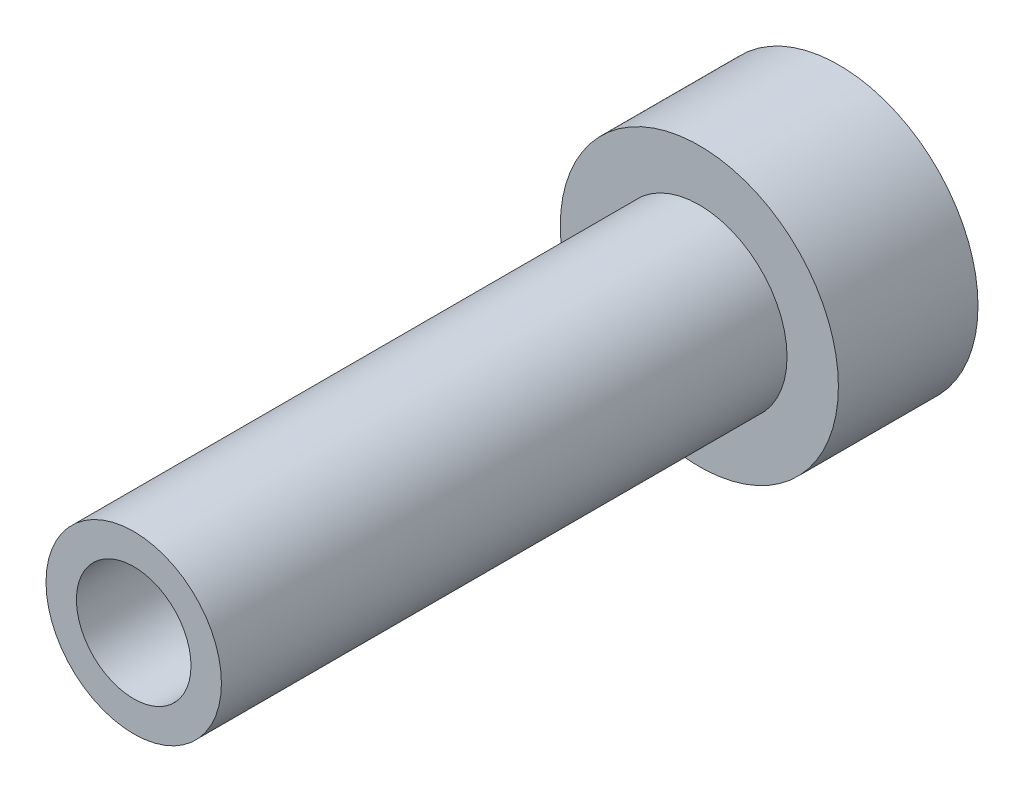
from build123d import *

# Parameters (mm, degrees)
BOSS_EXTRUDE1_START = 0.1
SKETCH1_R           = 3.884465816
BOSS_EXTRUDE1_DEPTH = 2.9
SKETCH2_R           = 3.884465816
SKETCH2_R_2         = 1.6
BOSS_EXTRUDE2_DEPTH = 1
SKETCH3_R           = 2.45
SKETCH3_R_2         = 1.6
BOSS_EXTRUDE3_DEPTH = 15.8


with BuildPart() as part:
    # Sketch1 → Boss-Extrude1 (new body)
    with BuildSketch(Plane.XY.offset(BOSS_EXTRUDE1_START)):
        with Locations((-0.001459351, 10.192904416)):
            Circle(SKETCH1_R)
        with BuildLine():
            Line((0.96845111, 13.081919272), (0.60411229, 12.721398629))
            ThreePointArc((0.60411229, 12.721398629), (0.587991908, 12.72520519), (0.571847603, 12.728908977))
            Line((0.571847603, 12.728908977), (0.404173908, 13.213267772))
            Line((0.404173908, 13.213267772), (0.114648145, 12.790310631))
            ThreePointArc((0.114648145, 12.790310631), (0.098098683, 12.790997601), (0.08154518, 12.791579126))
            Line((0.08154518, 12.791579126), (-0.174763937, 13.23545247))
            Line((-0.174763937, 13.23545247), (-0.379012427, 12.765345605))
            ThreePointArc((-0.379012427, 12.765345605), (-0.395392828, 12.762888154), (-0.411757242, 12.760326399))
            Line((-0.411757242, 12.760326399), (-0.747438103, 13.147671554))
            Line((-0.747438103, 13.147671554), (-0.859027247, 12.647405852))
            ThreePointArc((-0.859027247, 12.647405852), (-0.874646558, 12.641892799), (-0.89023043, 12.636280352))
            Line((-0.89023043, 12.636280352), (-1.293150653, 12.953097656))
            Line((-1.293150653, 12.953097656), (-1.308047329, 12.440754022))
            ThreePointArc((-1.308047329, 12.440754022), (-1.322341026, 12.432384623), (-1.336581115, 12.423924333))
            Line((-1.336581115, 12.423924333), (-1.792178114, 12.658763182))
            Line((-1.792178114, 12.658763182), (-1.709843917, 12.152859051))
            ThreePointArc((-1.709843917, 12.152859051), (-1.72229539, 12.141935797), (-1.734677021, 12.130933442))
            Line((-1.734677021, 12.130933442), (-2.226484333, 12.275306147))
            Line((-2.226484333, 12.275306147), (-2.049895036, 11.794126212))
            ThreePointArc((-2.049895036, 11.794126212), (-2.060054255, 11.781043899), (-2.070129925, 11.767897132))
            Line((-2.070129925, 11.767897132), (-2.580372352, 11.816585689))
            Line((-2.580372352, 11.816585689), (-2.315910352, 11.377521046))
            ThreePointArc((-2.315910352, 11.377521046), (-2.323410137, 11.362752503), (-2.330815684, 11.347936481))
            Line((-2.330815684, 11.347936481), (-2.841051735, 11.299181158))
            Line((-2.841051735, 11.299181158), (-2.498275379, 10.918100748))
            ThreePointArc((-2.498275379, 10.918100748), (-2.502844667, 10.902179748), (-2.507312436, 10.886229962))
            Line((-2.507312436, 10.886229962), (-2.999100852, 10.741792904))
            Line((-2.999100852, 10.741792904), (-2.590398969, 10.432469965))
            ThreePointArc((-2.590398969, 10.432469965), (-2.591872615, 10.415971935), (-2.593241129, 10.399464852))
            Line((-2.593241129, 10.399464852), (-3.048807394, 10.16456639))
            Line((-3.048807394, 10.16456639), (-2.588951536, 9.938180659))
            ThreePointArc((-2.588951536, 9.938180659), (-2.587276279, 9.921701881), (-2.585496075, 9.905234109))
            Line((-2.585496075, 9.905234109), (-2.988374839, 9.588364086))
            Line((-2.988374839, 9.588364086), (-2.493985393, 9.453097734))
            ThreePointArc((-2.493985393, 9.453097734), (-2.489221781, 9.437233793), (-2.484357202, 9.421400521))
            Line((-2.484357202, 9.421400521), (-2.819987375, 9.034011444))
            Line((-2.819987375, 9.034011444), (-2.308932865, 8.994753349))
            ThreePointArc((-2.308932865, 8.994753349), (-2.301253067, 8.98007761), (-2.293479931, 8.965451093))
            Line((-2.293479931, 8.965451093), (-2.549730965, 8.521544214))
            Line((-2.549730965, 8.521544214), (-2.040482233, 8.579713266))
            ThreePointArc((-2.040482233, 8.579713266), (-2.030163816, 8.566756147), (-2.019763064, 8.553865027))
            Line((-2.019763064, 8.553865027), (-2.187373379, 8.069484296))
            Line((-2.187373379, 8.069484296), (-1.698336, 8.222978114))
            ThreePointArc((-1.698336, 8.222978114), (-1.6857519, 8.21220792), (-1.673099443, 8.201518114))
            Line((-1.673099443, 8.201518114), (-1.746011165, 7.694170314))
            Line((-1.746011165, 7.694170314), (-1.294860225, 7.937441231))
            ThreePointArc((-1.294860225, 7.937441231), (-1.280465263, 7.929247225), (-1.266018393, 7.921145091))
            Line((-1.266018393, 7.921145091), (-1.241596303, 7.409167093))
            Line((-1.241596303, 7.409167093), (-0.844637572, 7.733422664))
            ThreePointArc((-0.844637572, 7.733422664), (-0.82895202, 7.728100999), (-0.813232885, 7.722879369))
            Line((-0.813232885, 7.722879369), (-0.69235966, 7.224775391))
            Line((-0.69235966, 7.224775391), (-0.363940261, 7.618296176))
            ThreePointArc((-0.363940261, 7.618296176), (-0.347531036, 7.616039191), (-0.331107766, 7.613886788))
            Line((-0.331107766, 7.613886788), (-0.11815208, 7.147659606))
            Line((-0.11815208, 7.147659606), (0.129858055, 7.596222737))
            ThreePointArc((0.129858055, 7.596222737), (0.14639788, 7.597112005), (0.162931705, 7.598106624))
            Line((0.162931705, 7.598106624), (0.460273079, 7.180606903))
            Line((0.460273079, 7.180606903), (0.618910217, 7.66800014))
            ThreePointArc((0.618910217, 7.66800014), (0.634982852, 7.67200352), (0.651029656, 7.676109212))
            Line((0.651029656, 7.676109212), (1.022010025, 7.32242648))
            Line((1.022010025, 7.32242648), (1.085540607, 7.831034163))
            ThreePointArc((1.085540607, 7.831034163), (1.100565143, 7.838006962), (1.115544953, 7.845075337))
            Line((1.115544953, 7.845075337), (1.546756122, 7.567992608))
            Line((1.546756122, 7.567992608), (1.512883986, 8.079432329))
            ThreePointArc((1.512883986, 8.079432329), (1.526317398, 8.089122534), (1.539688805, 8.098898121))
            Line((1.539688805, 8.098898121), (2.015545677, 7.908429889))
            Line((2.015545677, 7.908429889), (1.885495051, 8.404216884))
            ThreePointArc((1.885495051, 8.404216884), (1.896851821, 8.416274264), (1.908131547, 8.428403749))
            Line((1.908131547, 8.428403749), (2.411435415, 8.331434031))
            Line((2.411435415, 8.331434031), (2.189906668, 8.793649267))
            ThreePointArc((2.189906668, 8.793649267), (2.198776332, 8.807638037), (2.207556699, 8.821683028))
            Line((2.207556699, 8.821683028), (2.72011685, 8.821716563))
            Line((2.72011685, 8.821716563), (2.415116608, 9.233654376))
            ThreePointArc((2.415116608, 9.233654376), (2.421178593, 9.249068946), (2.427142255, 9.264521821))
            Line((2.427142255, 9.264521821), (2.93043343, 9.361557396))
            Line((2.93043343, 9.361557396), (2.552985195, 9.708329281))
            ThreePointArc((2.552985195, 9.708329281), (2.556020406, 9.724612528), (2.558951821, 9.74091478))
            Line((2.558951821, 9.74091478), (3.034783766, 9.931445277))
            Line((3.034783766, 9.931445277), (2.598529502, 10.200517994))
            ThreePointArc((2.598529502, 10.200517994), (2.598428238, 10.217081399), (2.598221457, 10.233643822))
            Line((2.598221457, 10.233643822), (3.029396365, 10.510782972))
            Line((3.029396365, 10.510782972), (2.550103437, 10.692431532))
            ThreePointArc((2.550103437, 10.692431532), (2.546869358, 10.70867645), (2.543531855, 10.724900436))
            Line((2.543531855, 10.724900436), (2.914465941, 11.078631708))
            Line((2.914465941, 11.078631708), (2.409457245, 11.166290859))
            ThreePointArc((2.409457245, 11.166290859), (2.403207239, 11.181630157), (2.396859639, 11.196929327))
            Line((2.396859639, 11.196929327), (2.69414638, 11.614467952))
            Line((2.69414638, 11.614467952), (2.181674246, 11.604969464))
            ThreePointArc((2.181674246, 11.604969464), (2.172634204, 11.618848739), (2.163505927, 11.632670142))
            Line((2.163505927, 11.632670142), (2.376400605, 12.098925186))
            Line((2.376400605, 12.098925186), (1.87498711, 11.992612359))
            ThreePointArc((1.87498711, 11.992612359), (1.863483764, 12.004529978), (1.851904729, 12.016374073))
            Line((1.851904729, 12.016374073), (1.972712775, 12.514493863))
            Line((1.972712775, 12.514493863), (1.50048031, 12.315209119))
            ThreePointArc((1.50048031, 12.315209119), (1.48692942, 12.324734349), (1.473318124, 12.334173059))
            Line((1.473318124, 12.334173059), (1.497673221, 12.846154249))
            Line((1.497673221, 12.846154249), (1.071689498, 12.561100258))
            ThreePointArc((1.071689498, 12.561100258), (1.056580829, 12.567888832), (1.041429218, 12.574581017))
            Line((1.041429218, 12.574581017), (0.96845111, 13.081919272))
        make_face(mode=Mode.SUBTRACT)
    extrude(amount=BOSS_EXTRUDE1_DEPTH)

    # Sketch2 → Boss-Extrude2 (add)
    with BuildSketch(Plane.XY.offset(3)):
        with Locations((-0.001459351, 10.192904416)):
            Circle(SKETCH2_R)
        with Locations((-0.001459351, 10.192904416)):
            Circle(SKETCH2_R_2, mode=Mode.SUBTRACT)
    extrude(amount=BOSS_EXTRUDE2_DEPTH)

    # Sketch3 → Boss-Extrude3 (add)
    with BuildSketch(Plane.XY.offset(4)):
        with Locations((-0.001459351, 10.192904416)):
            Circle(SKETCH3_R)
        with Locations((-0.001459351, 10.192904416)):
            Circle(SKETCH3_R_2, mode=Mode.SUBTRACT)
    extrude(amount=BOSS_EXTRUDE3_DEPTH)


solid = part.part
